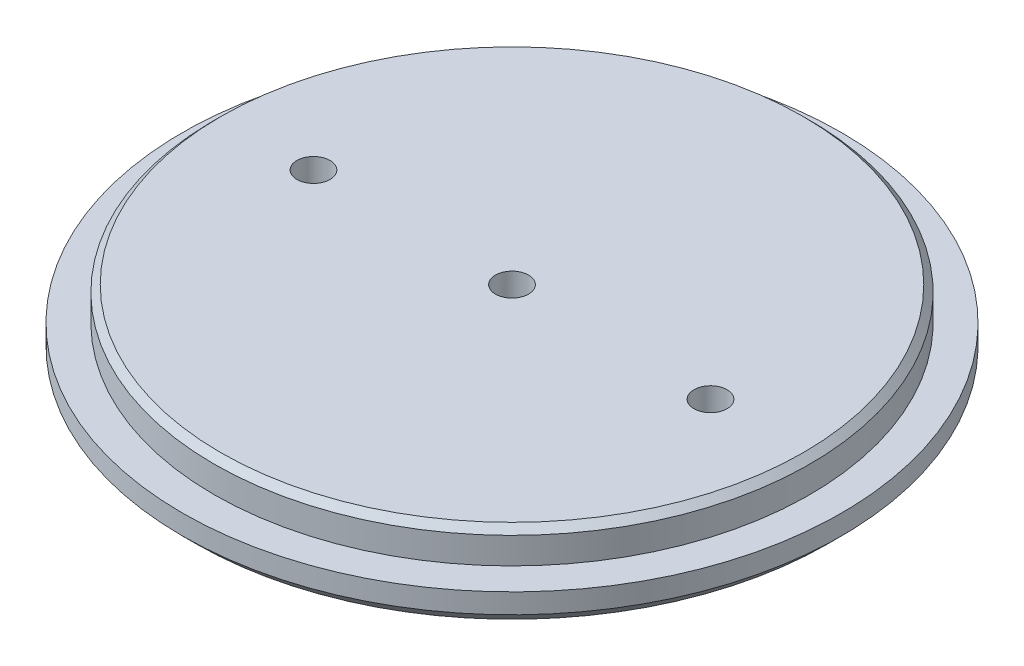
from build123d import *

# Parameters (mm, degrees)
SKETCH1_R           = 63.246
BOSS_EXTRUDE1_DEPTH = 6.35
SKETCH2_R           = 57.15
BOSS_EXTRUDE2_DEPTH = 6.35
CHAMFER1_SIZE       = 1.27
SKETCH4_R           = 3.175
CUT_EXTRUDE1_DEPTH  = 13.7
CHAMFER2_SIZE       = 2.54


with BuildPart() as part:
    # Sketch1 → Boss-Extrude1 (new body)
    with BuildSketch(Plane(origin=(0, 0, 0), x_dir=(1, 0, 0), z_dir=(0, 1, 0))):
        Circle(SKETCH1_R)
    extrude(amount=BOSS_EXTRUDE1_DEPTH)

    # Sketch2 → Boss-Extrude2 (add)
    with BuildSketch(Plane(origin=(0, 6.35, 0), x_dir=(1, 0, 0), z_dir=(0, 1, 0))):
        Circle(SKETCH2_R)
    extrude(amount=BOSS_EXTRUDE2_DEPTH)

    # Chamfer1
    chamfer1_edges = [part.edges().sort_by_distance(p)[0] for p in [
        (-57.15, 12.7, 0),
    ]]
    chamfer(chamfer1_edges, length=CHAMFER1_SIZE)

    # Sketch4 → Cut-Extrude1 (cut, through all)
    with BuildSketch(Plane.XZ):
        with Locations((-38.1, 0)):
            Circle(SKETCH4_R)
        Circle(SKETCH4_R)
        with Locations((38.1, 0)):
            Circle(SKETCH4_R)
    extrude(amount=-CUT_EXTRUDE1_DEPTH, mode=Mode.SUBTRACT)

    # Chamfer2
    chamfer2_edges = [part.edges().sort_by_distance(p)[0] for p in [
        (-63.246, 0, 0),
    ]]
    chamfer(chamfer2_edges, length=CHAMFER2_SIZE)


solid = part.part
